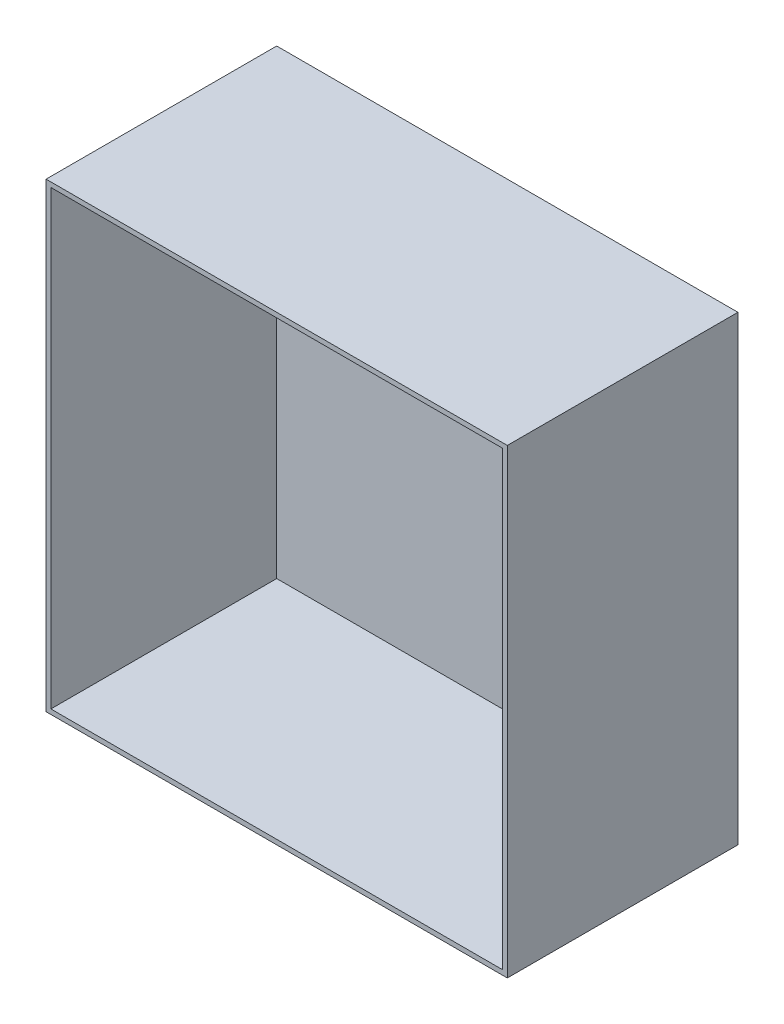
from build123d import *

# Parameters (mm, degrees)
SKETCH1_W           = 152.4
SKETCH1_H           = 152.4
BOSS_EXTRUDE1_DEPTH = 76.2
SHELL1_T            = -1.5875


with BuildPart() as part:
    # Sketch1 → Boss-Extrude1 (new body)
    with BuildSketch(Plane.XY):
        with Locations((76.2, 76.2)):
            Rectangle(SKETCH1_W, SKETCH1_H)
    extrude(amount=BOSS_EXTRUDE1_DEPTH)

    # Shell1
    shell1_openings = [part.faces().sort_by_distance(p)[0] for p in [
        (76.2, 76.2, 76.2),
    ]]
    offset(amount=SHELL1_T, openings=shell1_openings, kind=Kind.INTERSECTION)


solid = part.part
